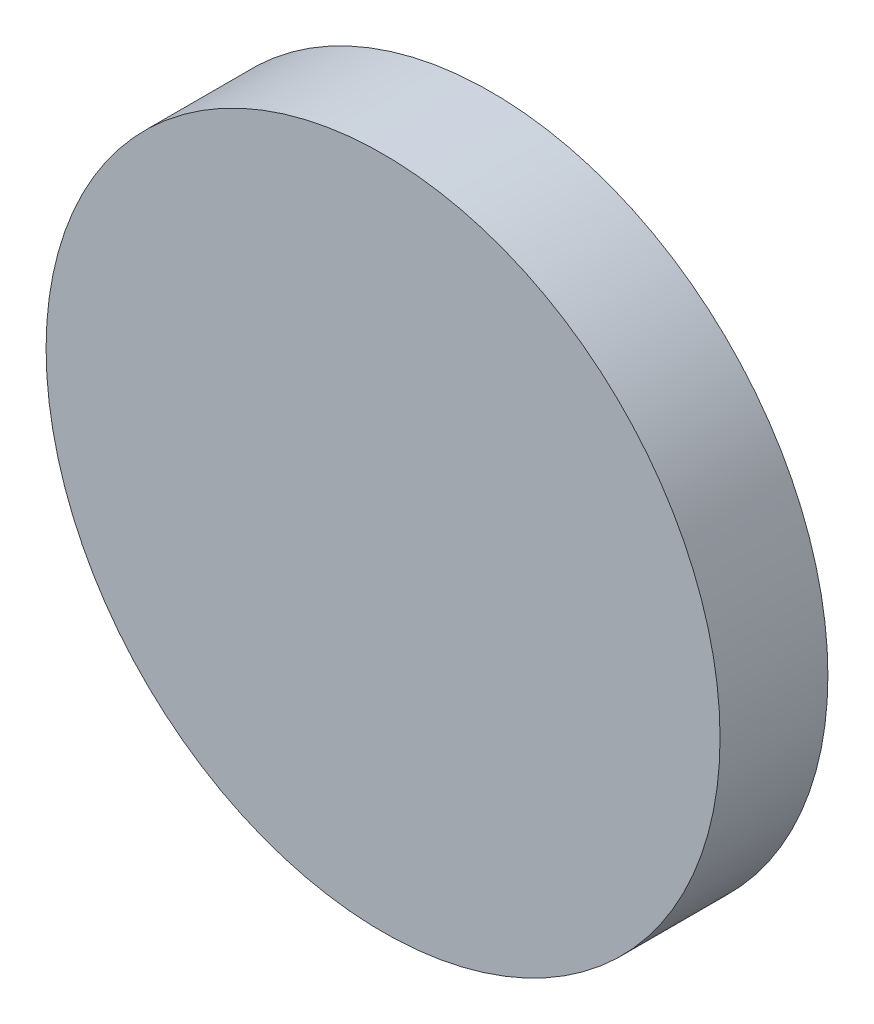
from build123d import *

# Parameters (mm, degrees)
SKETCH_1_R      = 12.5
EXTRUDE_1_DEPTH = 4


with BuildPart() as part:
    # Эскиз1 → Бобышка-Вытянуть1 (new body)
    with BuildSketch(Plane.XY):
        Circle(SKETCH_1_R)
    extrude(amount=EXTRUDE_1_DEPTH)


solid = part.part
